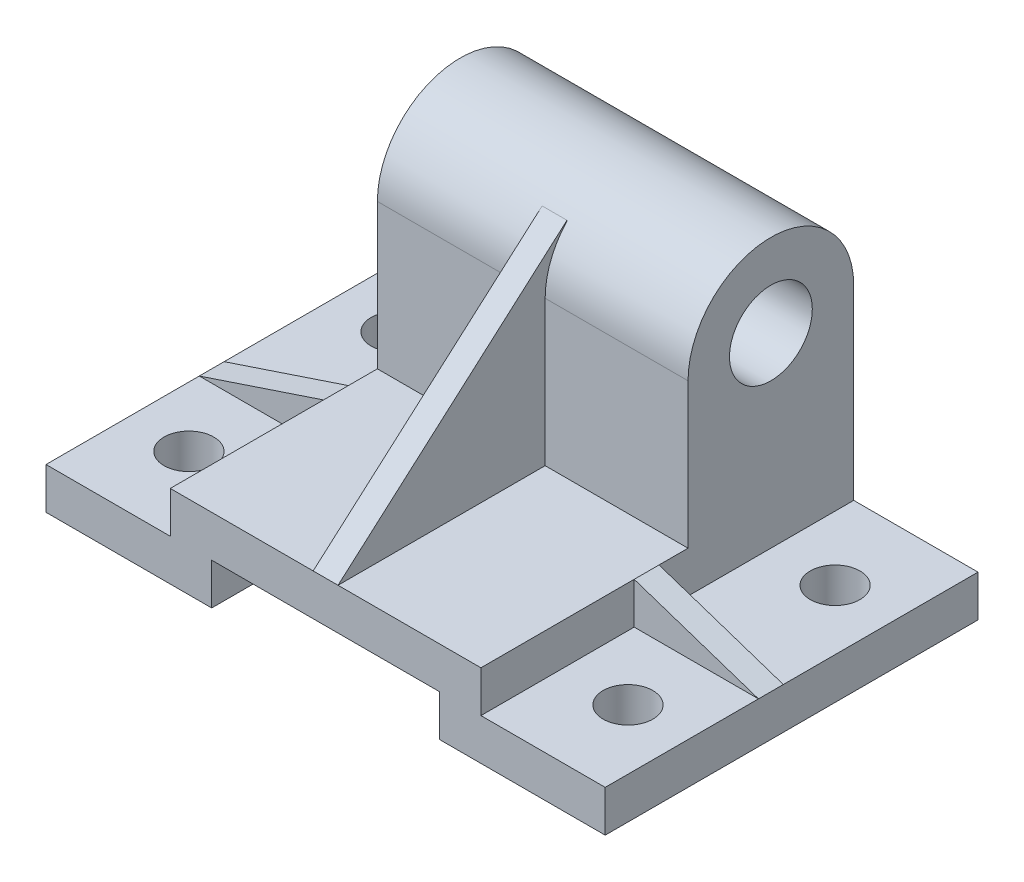
from build123d import *

# Parameters (mm, degrees)
CROQUIS2_W              = 135
CROQUIS2_H              = 90
CROQUIS2_R              = 6
SALIENTE_EXTRUIR1_DEPTH = 10
CROQUIS3_W              = 75
CROQUIS3_H              = 90
SALIENTE_EXTRUIR2_DEPTH = 10
CROQUIS4_W              = 55
CROQUIS4_H              = 20
CORTAR_EXTRUIR1_DEPTH   = 91
SALIENTE_EXTRUIR3_DEPTH = 6
CROQUIS11_R             = 10
SALIENTE_EXTRUIR4_DEPTH = 37.5
SALIENTE_EXTRUIR5_DEPTH = 3


with BuildPart() as part:
    # Croquis2 → Saliente-Extruir1 (new body)
    with BuildSketch(Plane(origin=(0, 0, 0), x_dir=(1, 0, 0), z_dir=(0, 1, 0))):
        Rectangle(CROQUIS2_W, CROQUIS2_H)
        with Locations((-53, -25)):
            Circle(CROQUIS2_R, mode=Mode.SUBTRACT)
        with Locations((53, -25)):
            Circle(CROQUIS2_R, mode=Mode.SUBTRACT)
        with Locations((53, 25)):
            Circle(CROQUIS2_R, mode=Mode.SUBTRACT)
        with Locations((-53, 25)):
            Circle(CROQUIS2_R, mode=Mode.SUBTRACT)
    extrude(amount=SALIENTE_EXTRUIR1_DEPTH)

    # Croquis3 → Saliente-Extruir2 (add)
    with BuildSketch(Plane(origin=(0, 10, 0), x_dir=(1, 0, 0), z_dir=(0, 1, 0))):
        Rectangle(CROQUIS3_W, CROQUIS3_H)
    extrude(amount=SALIENTE_EXTRUIR2_DEPTH)

    # Croquis4 → Cortar-Extruir1 (cut, through all)
    with BuildSketch(Plane.XY.offset(45)):
        Rectangle(CROQUIS4_W, CROQUIS4_H)
    extrude(amount=-CORTAR_EXTRUIR1_DEPTH, mode=Mode.SUBTRACT)

    # Croquis9 → Saliente-Extruir3 (add)
    with BuildSketch(Plane.XY.offset(8)):
        Polygon((37.5, 20), (37.5, 10), (67.5, 10), align=None)
    saliente_extruir3 = extrude(amount=-SALIENTE_EXTRUIR3_DEPTH)

    # Simetría1: Saliente-Extruir3 across plane
    add(saliente_extruir3.mirror(Plane(origin=(0, 0, 0), x_dir=(0, 0, 1), z_dir=(1, 0, 0))))

    # Croquis11 → Saliente-Extruir4 (add, symmetric)
    with BuildSketch(Plane(origin=(0, 0, 0), x_dir=(0, 0, -1), z_dir=(1, 0, 0))):
        with BuildLine():
            Line((45, 20), (45, 55))
            ThreePointArc((45, 55), (25, 75), (5, 55))
            Line((5, 55), (5, 20))
            Line((5, 20), (45, 20))
        make_face()
        with Locations((25, 55)):
            Circle(CROQUIS11_R, mode=Mode.SUBTRACT)
    extrude(amount=SALIENTE_EXTRUIR4_DEPTH, both=True)

    # Croquis12 → Saliente-Extruir5 (add, symmetric)
    with BuildSketch(Plane(origin=(0, 0, 0), x_dir=(0, 0, -1), z_dir=(1, 0, 0))):
        Polygon((-45, 20), (10.271335942, 68.678995905), (5, 20), align=None)
    extrude(amount=SALIENTE_EXTRUIR5_DEPTH, both=True)


solid = part.part
